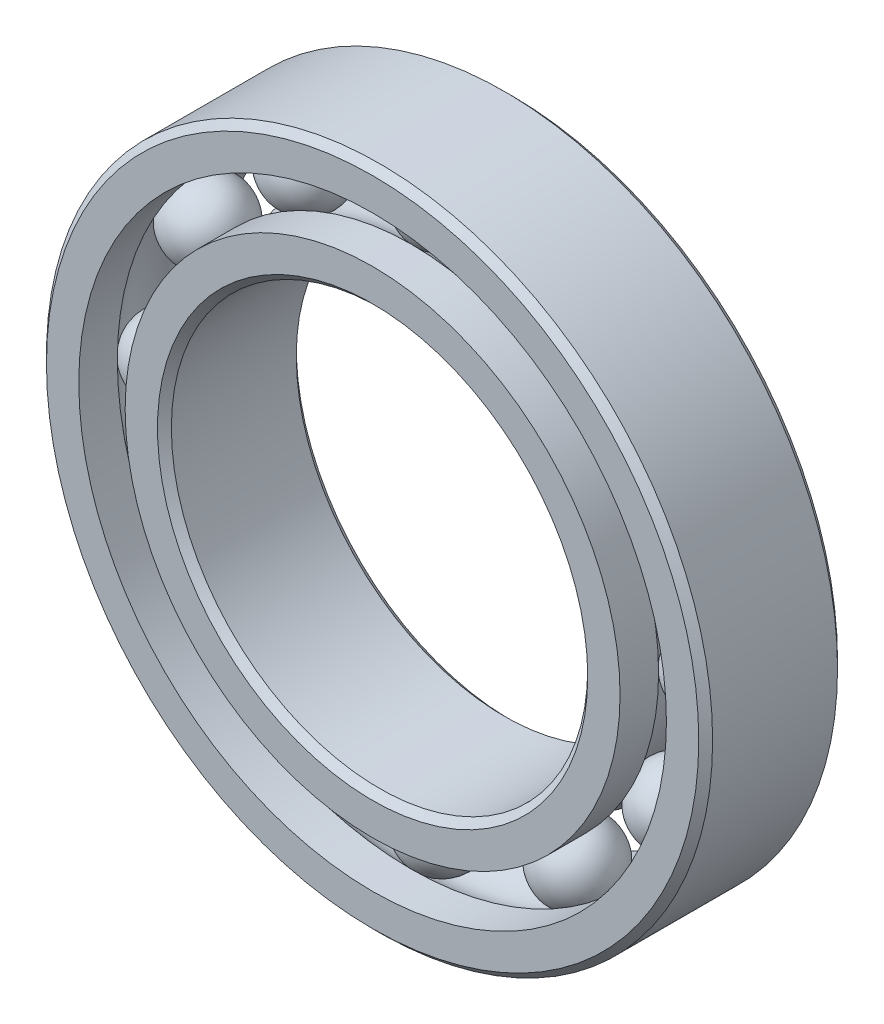
from build123d import *

# Parameters (mm, degrees)
CIRPATTERN1_COUNT = 12


with BuildPart() as part:
    # Sketch1 → Revolve1 (revolve)
    with BuildSketch(Plane(origin=(0, 0, 0), x_dir=(0, 0, -1), z_dir=(1, 0, 0))):
        with BuildLine():
            Line((2.25, 12), (-2.25, 12))
            Line((-2.25, 12), (-2.5, 11.75))
            Line((-2.5, 11.75), (-2.5, 10.585164835))
            Line((-2.5, 10.585164835), (-1.111111111, 10.585164835))
            ThreePointArc((-1.111111111, 10.585164835), (0, 11.139988562), (1.111111111, 10.585164835))
            Line((1.111111111, 10.585164835), (2.5, 10.585164835))
            Line((2.5, 10.585164835), (2.5, 11.75))
            Line((2.5, 11.75), (2.25, 12))
        make_face()
    revolve(axis=Axis((0, 0, 2.5), (0, 0, -1)))


with BuildPart() as body_2:
    # Sketch3 → Revolve3 (revolve)
    with BuildSketch(Plane(origin=(0, 0, 0), x_dir=(0, 0, -1), z_dir=(1, 0, 0))):
        with BuildLine():
            Line((-2.5, 8.914835165), (-1.111111111, 8.914835165))
            ThreePointArc((-1.111111111, 8.914835165), (0, 8.360011438), (1.111111111, 8.914835165))
            Line((1.111111111, 8.914835165), (2.5, 8.914835165))
            Line((2.5, 8.914835165), (2.5, 7.75))
            Line((2.5, 7.75), (2.25, 7.5))
            Line((2.25, 7.5), (-2.25, 7.5))
            Line((-2.25, 7.5), (-2.5, 7.75))
            Line((-2.5, 7.75), (-2.5, 8.914835165))
        make_face()
    revolve(axis=Axis((0, 0, 2.5), (0, 0, -1)))


with BuildPart() as body_3:
    # Sketch4 → Revolve4 (revolve)
    with BuildSketch(Plane(origin=(0, 0, 0), x_dir=(0, 0, -1), z_dir=(1, 0, 0))):
        with BuildLine():
            Line((-1.389988562, 9.75), (1.389988562, 9.75))
            ThreePointArc((1.389988562, 9.75), (0, 11.139988562), (-1.389988562, 9.75))
        make_face()
    revolve(axis=Axis((0, 9.75, 1.389988562), (0, 0, -1)))


with BuildPart() as cirpattern1_1:
    # CirPattern1: pattern copy
    add(body_3.part.rotate(Axis((0, 0, -2.5), (0, 0, 1)), 1 * 360 / CIRPATTERN1_COUNT))


with BuildPart() as cirpattern1_2:
    # CirPattern1: pattern copy
    add(body_3.part.rotate(Axis((0, 0, -2.5), (0, 0, 1)), 2 * 360 / CIRPATTERN1_COUNT))


with BuildPart() as cirpattern1_3:
    # CirPattern1: pattern copy
    add(body_3.part.rotate(Axis((0, 0, -2.5), (0, 0, 1)), 3 * 360 / CIRPATTERN1_COUNT))


with BuildPart() as cirpattern1_4:
    # CirPattern1: pattern copy
    add(body_3.part.rotate(Axis((0, 0, -2.5), (0, 0, 1)), 4 * 360 / CIRPATTERN1_COUNT))


with BuildPart() as cirpattern1_5:
    # CirPattern1: pattern copy
    add(body_3.part.rotate(Axis((0, 0, -2.5), (0, 0, 1)), 5 * 360 / CIRPATTERN1_COUNT))


with BuildPart() as cirpattern1_6:
    # CirPattern1: pattern copy
    add(body_3.part.rotate(Axis((0, 0, -2.5), (0, 0, 1)), 6 * 360 / CIRPATTERN1_COUNT))


with BuildPart() as cirpattern1_7:
    # CirPattern1: pattern copy
    add(body_3.part.rotate(Axis((0, 0, -2.5), (0, 0, 1)), 7 * 360 / CIRPATTERN1_COUNT))


with BuildPart() as cirpattern1_8:
    # CirPattern1: pattern copy
    add(body_3.part.rotate(Axis((0, 0, -2.5), (0, 0, 1)), 8 * 360 / CIRPATTERN1_COUNT))


with BuildPart() as cirpattern1_9:
    # CirPattern1: pattern copy
    add(body_3.part.rotate(Axis((0, 0, -2.5), (0, 0, 1)), 9 * 360 / CIRPATTERN1_COUNT))


with BuildPart() as cirpattern1_10:
    # CirPattern1: pattern copy
    add(body_3.part.rotate(Axis((0, 0, -2.5), (0, 0, 1)), 10 * 360 / CIRPATTERN1_COUNT))


with BuildPart() as cirpattern1_11:
    # CirPattern1: pattern copy
    add(body_3.part.rotate(Axis((0, 0, -2.5), (0, 0, 1)), 11 * 360 / CIRPATTERN1_COUNT))


solid = Compound([part.part, body_2.part, body_3.part, cirpattern1_1.part, cirpattern1_2.part, cirpattern1_3.part, cirpattern1_4.part, cirpattern1_5.part, cirpattern1_6.part, cirpattern1_7.part, cirpattern1_8.part, cirpattern1_9.part, cirpattern1_10.part, cirpattern1_11.part])
